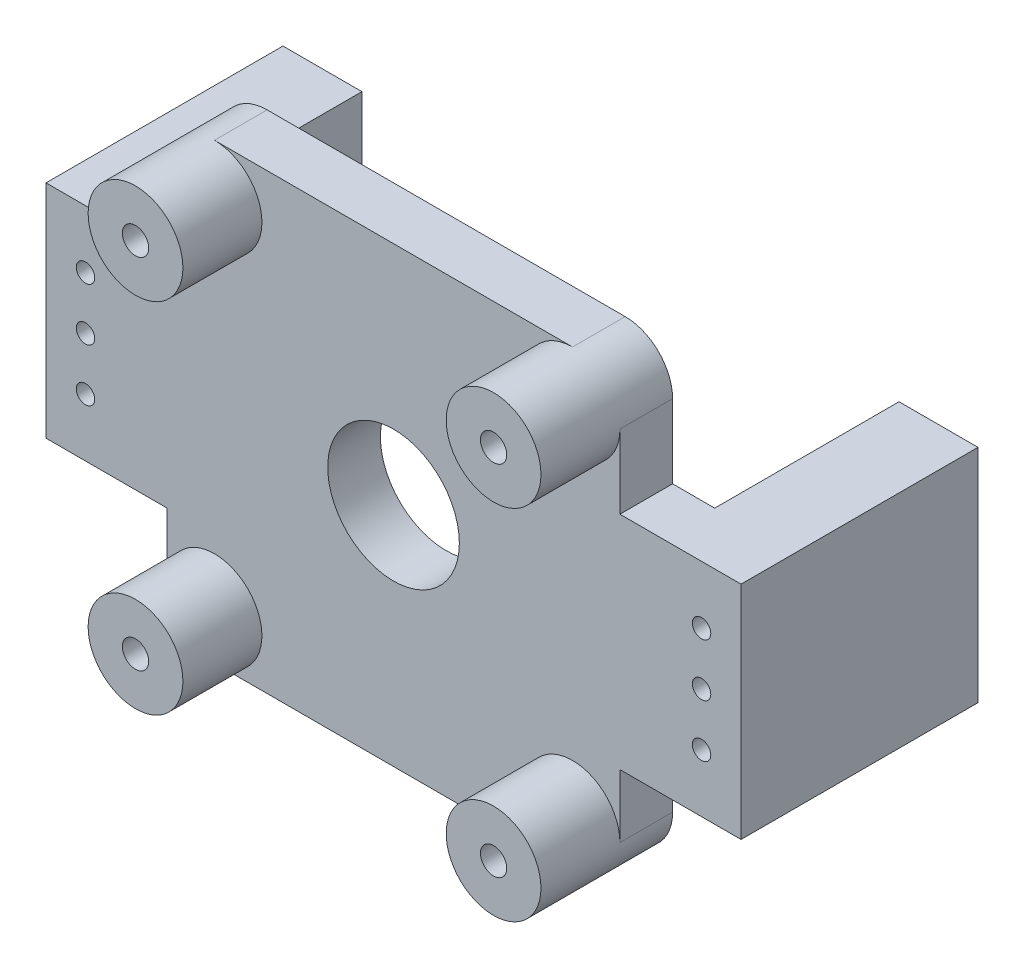
from build123d import *

# Parameters (mm, degrees)
SKETCH_1_W          = 86
SKETCH_1_H          = 86
SKETCH_1_R          = 2
EXTRUDE_1_DEPTH     = 10
FILLET_1_R          = 5
SKETCH_2_R          = 9
SKETCH_2_R_2        = 2.5
EXTRUDE_2_DEPTH     = 15
SKETCH_3_R          = 12.5
CUT_EXTRUDE_1_DEPTH = 16
SKETCH_8_W          = 10
SKETCH_8_H          = 42
EXTRUDE_7_DEPTH     = 35
EXTRUDE_7_2_DEPTH   = 35
SKETCH_9_W          = 23
SKETCH_9_H          = 42
EXTRUDE_8_DEPTH     = 10
CUT_EXTRUDE_2_DEPTH = 10
SKETCH_11_W         = 35
SKETCH_11_H         = 42
EXTRUDE_9_DEPTH     = 5
SKETCH_12_W         = 35
SKETCH_12_H         = 42
EXTRUDE_10_DEPTH    = 5
SKETCH_13_R         = 1.75
CUT_EXTRUDE_3_DEPTH = 45


with BuildPart() as part:
    # 草图1 → 凸台-拉伸1 (new body)
    with BuildSketch(Plane.XY):
        Rectangle(SKETCH_1_W, SKETCH_1_H)
        with Locations((-34, 34)):
            Circle(SKETCH_1_R, mode=Mode.SUBTRACT)
        with Locations((34, 34)):
            Circle(SKETCH_1_R, mode=Mode.SUBTRACT)
        with Locations((34, -34)):
            Circle(SKETCH_1_R, mode=Mode.SUBTRACT)
        with Locations((-34, -34)):
            Circle(SKETCH_1_R, mode=Mode.SUBTRACT)
    extrude(amount=EXTRUDE_1_DEPTH)

    # 圆角1
    fillet_1_edges = [part.edges().sort_by_distance(p)[0] for p in [
        (-43, 43, 5),
        (43, 43, 5),
        (43, -43, 5),
        (-43, -43, 5),
    ]]
    fillet(fillet_1_edges, radius=FILLET_1_R)

    # 草图2 → 凸台-拉伸2 (add)
    with BuildSketch(Plane.XY.offset(10)):
        with Locations((-34, 34)):
            Circle(SKETCH_2_R)
        with Locations((-34, 34)):
            Circle(SKETCH_2_R_2, mode=Mode.SUBTRACT)
        with Locations((34, 34)):
            Circle(SKETCH_2_R)
        with Locations((34, 34)):
            Circle(SKETCH_2_R_2, mode=Mode.SUBTRACT)
        with Locations((34, -34)):
            Circle(SKETCH_2_R)
        with Locations((34, -34)):
            Circle(SKETCH_2_R_2, mode=Mode.SUBTRACT)
        with Locations((-34, -34)):
            Circle(SKETCH_2_R)
        with Locations((-34, -34)):
            Circle(SKETCH_2_R_2, mode=Mode.SUBTRACT)
    extrude(amount=EXTRUDE_2_DEPTH)

    # 草图3 → 切除-拉伸1 (cut)
    with BuildSketch(Plane.XY.offset(10)):
        Circle(SKETCH_3_R)
    extrude(amount=-CUT_EXTRUDE_1_DEPTH, mode=Mode.SUBTRACT)



with BuildPart() as body_2:
    # 草图8 → 凸台-拉伸7 (new body)
    with BuildSketch(Plane(origin=(0, 0, 0), x_dir=(-1, 0, 0), z_dir=(0, 0, -1))):
        with Locations((-61, -1)):
            Rectangle(SKETCH_8_W, SKETCH_8_H)
    extrude(amount=EXTRUDE_7_DEPTH)


with BuildPart() as body_3:
    # 草图8 → Extrude 7 2 (new body)
    with BuildSketch(Plane(origin=(0, 0, 0), x_dir=(-1, 0, 0), z_dir=(0, 0, -1))):
        with Locations((61, -1)):
            Rectangle(SKETCH_8_W, SKETCH_8_H)
    extrude(amount=EXTRUDE_7_2_DEPTH)


with BuildPart() as part_1:
    add(part.part)

    add(body_2.part)  # 凸台-拉伸8 merges body 2

    add(body_3.part)  # 凸台-拉伸8 merges body 3
    # 草图9 → 凸台-拉伸8 (add)
    with BuildSketch(Plane.XY):
        with Locations((-54.5, -1)):
            Rectangle(SKETCH_9_W, SKETCH_9_H)
        with Locations((54.5, -1)):
            Rectangle(SKETCH_9_W, SKETCH_9_H)
    extrude(amount=EXTRUDE_8_DEPTH)

    # 草图10 → 切除-拉伸2 (cut)
    with BuildSketch(Plane.XY.offset(10)):
        with BuildLine():
            Line((34, 43), (43, 43))
            Line((43, 43), (43, 34))
            ThreePointArc((43, 34), (40.363961031, 40.363961031), (34, 43))
        make_face()
        with BuildLine():
            Line((-43, 43), (-34, 43))
            ThreePointArc((-34, 43), (-40.363961031, 40.363961031), (-43, 34))
            Line((-43, 34), (-43, 43))
        make_face()
        with BuildLine():
            Line((-43, -43), (-34, -43))
            ThreePointArc((-34, -43), (-40.363961031, -40.363961031), (-43, -34))
            Line((-43, -34), (-43, -43))
        make_face()
        with BuildLine():
            Line((34, -43), (43, -43))
            Line((43, -43), (43, -34))
            ThreePointArc((43, -34), (40.363961031, -40.363961031), (34, -43))
        make_face()
    extrude(amount=-CUT_EXTRUDE_2_DEPTH, mode=Mode.SUBTRACT)

    # 草图11 → 凸台-拉伸9 (add)
    with BuildSketch(Plane.ZY.offset(-56)):
        with Locations((-17.5, -1)):
            Rectangle(SKETCH_11_W, SKETCH_11_H)
    extrude(amount=EXTRUDE_9_DEPTH)

    # 草图12 → 凸台-拉伸10 (add)
    with BuildSketch(Plane(origin=(-56, 0, 0), x_dir=(0, 0, -1), z_dir=(1, 0, 0))):
        with Locations((17.5, -1)):
            Rectangle(SKETCH_12_W, SKETCH_12_H)
    extrude(amount=EXTRUDE_10_DEPTH)

    # 草图13 → 切除-拉伸3 (cut)
    with BuildSketch(Plane(origin=(0, 0, -35), x_dir=(-1, 0, 0), z_dir=(0, 0, -1))):
        with Locations((58.5, 9)):
            Circle(SKETCH_13_R)
        with Locations((58.5, -1)):
            Circle(SKETCH_13_R)
        with Locations((58.5, -11)):
            Circle(SKETCH_13_R)
        with Locations((-58.5, -11)):
            Circle(SKETCH_13_R)
        with Locations((-58.5, -1)):
            Circle(SKETCH_13_R)
        with Locations((-58.5, 9)):
            Circle(SKETCH_13_R)
    extrude(amount=-CUT_EXTRUDE_3_DEPTH, mode=Mode.SUBTRACT)


solid = part_1.part
